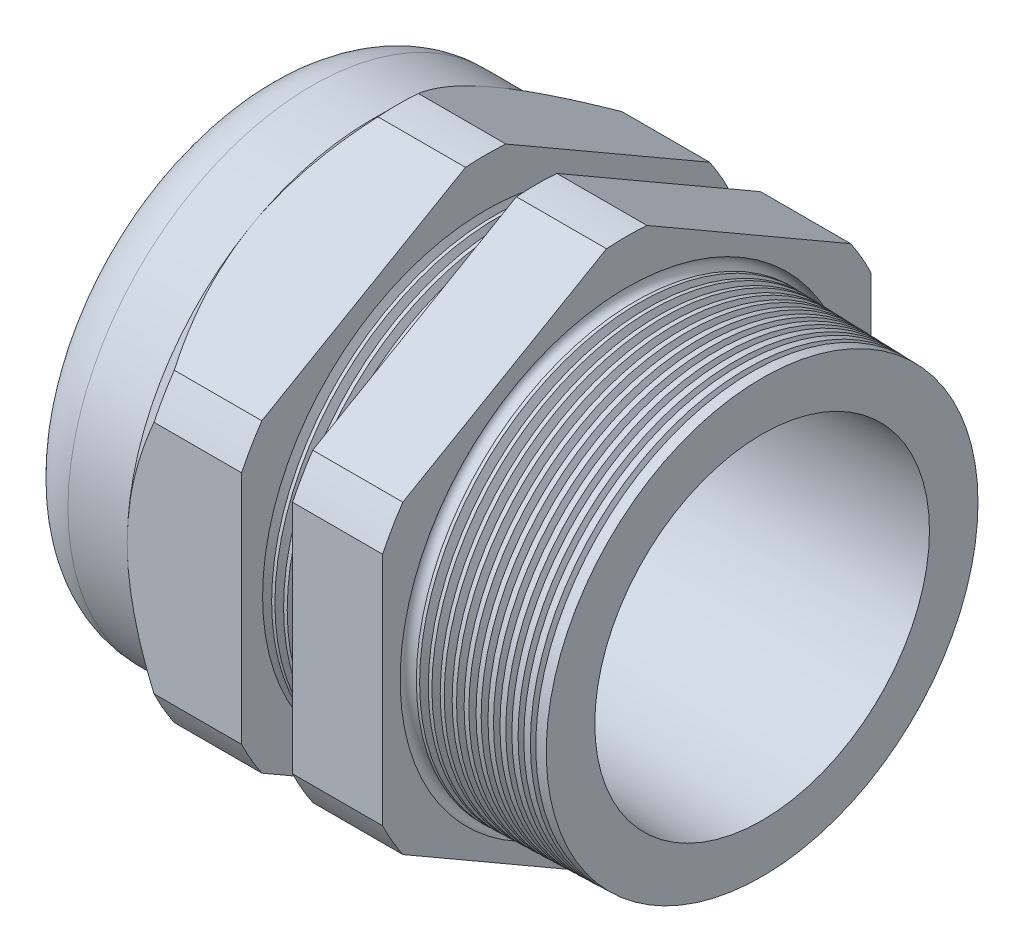
from build123d import *

# Parameters (mm, degrees)
LPATTERN6_COUNT    = 4
LPATTERN6_PITCH    = 1.5748
LPATTERN7_COUNT    = 11
LPATTERN7_PITCH    = 1.5748
SKETCH12_OUTSIDE_W = 171.2
SKETCH12_OUTSIDE_H = 171.2
CUT_EXTRUDE2_DEPTH = 53.05603
FILLET4_R          = 7.112
SKETCH19_OUTSIDE_W = 98.628
SKETCH19_OUTSIDE_H = 105.78
SKETCH19_OUTSIDE_R = 32.512
CUT_EXTRUDE3_DEPTH = 3.99796
CUT_EXTRUDE3_DRAFT = -45
SKETCH28_R         = 1.0795


with BuildPart() as part:
    # Sketch10 → Revolve2 (revolve)
    with BuildSketch(Plane.XY, mode=Mode.PRIVATE) as revolve2_sk:
        Polygon((-41.89603, 20.955), (-26.65603, 20.955), (10.16, 22.2885), (10.16, 28.753938326), (-7.874, 29.226175236), (-7.874, 65.024), (-19.873976, 65.024), (-19.873976, 29.540405666), (-26.65603, 29.718), (-26.65603, 65.024), (-41.89603, 65.024), (-41.89603, 32.512), (-56.896, 32.512), (-56.896, 22.2885), (-41.89603, 22.2885), align=None)
    revolve(revolve2_sk.sketch.rotate(Axis((0, 0, 0), (-1, 0, 0)), 90), axis=Axis((0, 0, 0), (-1, 0, 0)))  # turned: the seam where the file's is

    # Sketch26 → Cut-Revolve1 (revolve, cut)
    with BuildSketch(Plane.XY, mode=Mode.PRIVATE) as cut_revolve1_sk:
        Polygon((-26.65603, 29.718), (-25.483256271, 29.687289839), (-26.096238915, 28.686993077), align=None)
    cut_revolve1 = revolve(cut_revolve1_sk.sketch.rotate(Axis((0, 0, 0), (-1, 0, 0)), 90), axis=Axis((0, 0, 0), (-1, 0, 0)), mode=Mode.SUBTRACT)  # turned: the seam where the file's is

    # LPattern6: Cut-Revolve1 ×4
    with Locations(*[(i * LPATTERN6_PITCH, 0, 0) for i in range(1, LPATTERN6_COUNT)]):
        add(cut_revolve1, mode=Mode.SUBTRACT)

    # Sketch27 → Cut-Revolve2 (revolve, cut)
    with BuildSketch(Plane.XY, mode=Mode.PRIVATE) as cut_revolve2_sk:
        Polygon((-7.874, 29.226175236), (-6.701226271, 29.195465075), (-7.314208915, 28.195168313), align=None)
    cut_revolve2 = revolve(cut_revolve2_sk.sketch.rotate(Axis((0, 0, 0), (-1, 0, 0)), 90), axis=Axis((0, 0, 0), (-1, 0, 0)), mode=Mode.SUBTRACT)  # turned: the seam where the file's is

    # LPattern7: Cut-Revolve2 ×11
    with Locations(*[(i * LPATTERN7_PITCH, 0, 0) for i in range(1, LPATTERN7_COUNT)]):
        add(cut_revolve2, mode=Mode.SUBTRACT)

    # Sketch12 outside → Cut-Extrude2 (cut, through all)
    with BuildSketch(Plane.ZY.offset(41.89603)):
        Rectangle(SKETCH12_OUTSIDE_W, SKETCH12_OUTSIDE_H)
        with BuildLine():
            Line((-2.69124706, 35.987831689), (-29.82075294, 20.324604167))
            ThreePointArc((-29.82075294, 20.324604167), (-31.2534019, 18.04416), (-32.512, 15.663227523))
            Line((-32.512, 15.663227523), (-32.512, -15.663227523))
            ThreePointArc((-32.512, -15.663227523), (-31.2534019, -18.04416), (-29.82075294, -20.324604167))
            Line((-29.82075294, -20.324604167), (-2.69124706, -35.987831689))
            ThreePointArc((-2.69124706, -35.987831689), (0, -36.08832), (2.69124706, -35.987831689))
            Line((2.69124706, -35.987831689), (29.82075294, -20.324604167))
            ThreePointArc((29.82075294, -20.324604167), (31.2534019, -18.04416), (32.512, -15.663227523))
            Line((32.512, -15.663227523), (32.512, 15.663227523))
            ThreePointArc((32.512, 15.663227523), (31.2534019, 18.04416), (29.82075294, 20.324604167))
            Line((29.82075294, 20.324604167), (2.69124706, 35.987831689))
            ThreePointArc((2.69124706, 35.987831689), (0, 36.08832), (-2.69124706, 35.987831689))
        make_face(mode=Mode.SUBTRACT)
    extrude(amount=-CUT_EXTRUDE2_DEPTH, mode=Mode.SUBTRACT)

    # Fillet4
    fillet4_edges = [part.edges().sort_by_distance(p)[0] for p in [
        (-56.896, 0, 32.512),
    ]]
    fillet(fillet4_edges, radius=FILLET4_R)


with BuildPart() as body_2:
    # Sketch23 → Revolve6 (revolve)
    with BuildSketch(Plane.XY, mode=Mode.PRIVATE) as revolve6_sk:
        with BuildLine():
            Line((-55.9054, 22.2885), (-41.89603, 22.2885))
            Line((-41.89603, 22.2885), (-41.89603, 20.955))
            Line((-41.89603, 20.955), (-56.134, 20.955))
            Line((-56.134, 20.955), (-56.134, 22.0599))
            ThreePointArc((-56.134, 22.0599), (-56.06704461, 22.22154461), (-55.9054, 22.2885))
        make_face()
    revolve(revolve6_sk.sketch.rotate(Axis((0, 0, 0), (-1, 0, 0)), 90), axis=Axis((0, 0, 0), (-1, 0, 0)))  # turned: the seam where the file's is


with BuildPart() as cut_extrude3_tool:
    # Sketch19 outside → Cut-Extrude3 (with draft: the straight prism first)
    with BuildSketch(Plane.ZY.offset(41.89603)):
        Rectangle(SKETCH19_OUTSIDE_W, SKETCH19_OUTSIDE_H)
        Circle(SKETCH19_OUTSIDE_R, mode=Mode.SUBTRACT)
    extrude(amount=-CUT_EXTRUDE3_DEPTH)
    # Cut-Extrude3: the draft: its side faces are tilted about the plane it starts from
    cut_extrude3_sides = [cut_extrude3_tool.faces().sort_by_distance(p)[0] for p in [
        (-39.89705, -52.89, 0),
        (-39.89705, 0, 49.314),
        (-39.89705, 52.89, 0),
        (-39.89705, 0, -49.314),
        (-39.89705, 0, -32.512),
    ]]
    draft(cut_extrude3_sides, Plane.ZY.offset(41.89603), CUT_EXTRUDE3_DRAFT)


with BuildPart() as part_1:
    add(part.part)

    # Cut-Extrude3: cut by cut_extrude3_tool
    add(cut_extrude3_tool.part, mode=Mode.SUBTRACT)

    # Sketch28 → Cut-Revolve3 (revolve, cut)
    with BuildSketch(Plane.XY, mode=Mode.PRIVATE) as cut_revolve3_sk:
        with Locations((-7.8486, -29.099175236)):
            Circle(SKETCH28_R)
    revolve(cut_revolve3_sk.sketch.rotate(Axis((10.16, 0, 0), (-1, 0, 0)), 90), axis=Axis((10.16, 0, 0), (-1, 0, 0)), mode=Mode.SUBTRACT)  # turned: the seam where the file's is


solid = Compound([body_2.part, part_1.part])
